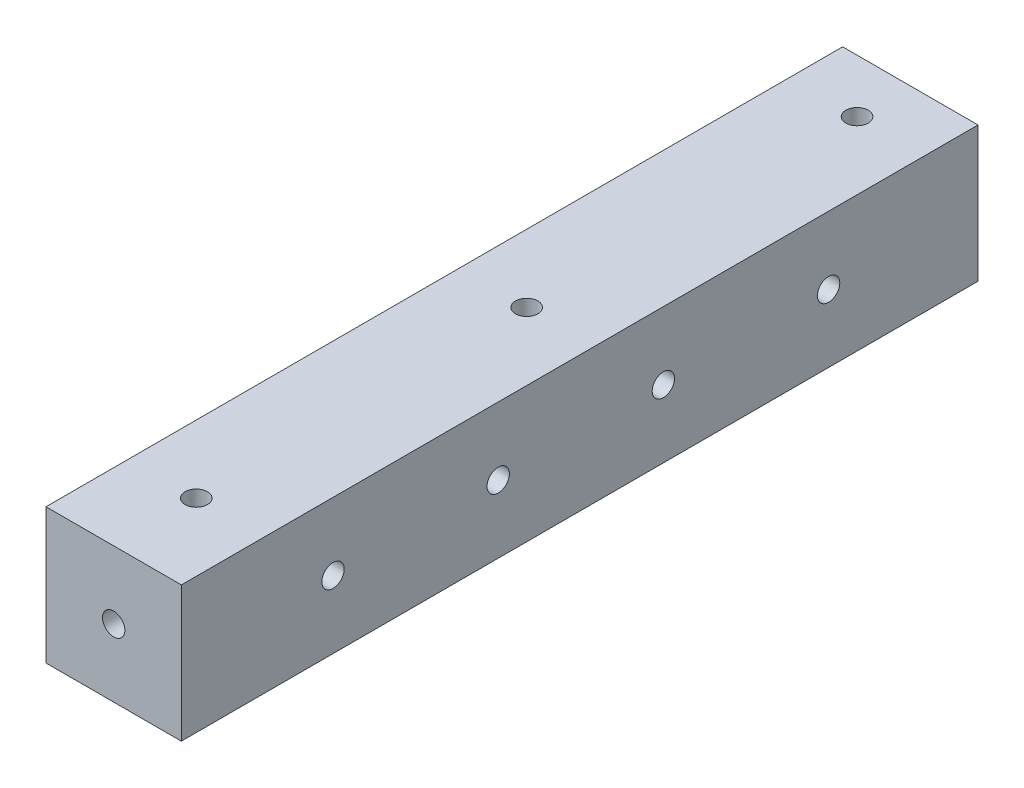
from build123d import *

# Parameters (mm, degrees)
SKETCH1_W                   = 25.4
SKETCH1_H                   = 25.4
BOSS_EXTRUDE1_DEPTH         = 77.5
M5X0_8_TAPPED_HOLE2_D       = 4.2
M5X0_8_TAPPED_HOLE1_D       = 4.2
M5X0_8_TAPPED_HOLE1_DEPTH   = 10
M5X0_8_TAPPED_HOLE1_TIP     = 1.2618073
SKETCH13_W                  = 25.4
SKETCH13_H                  = 5.5
CUT_EXTRUDE1_DEPTH          = 26.4
TAP_DRILL_FOR_M5X0_8_TAP1_D = 4.2


with BuildPart() as part:
    # Sketch1 → Boss-Extrude1 (new body, symmetric)
    with BuildSketch(Plane.XY):
        Rectangle(SKETCH1_W, SKETCH1_H)
    extrude(amount=BOSS_EXTRUDE1_DEPTH, both=True)

    # M5x0.8 Tapped Hole2 (through all)
    with Locations(Plane(origin=(0, -12.7, 0), x_dir=(-1, 0, 0), z_dir=(0, -1, 0))):
        with Locations((0, -62), (0, 0), (0, 62)):
            Hole(M5X0_8_TAPPED_HOLE2_D / 2)

    # M5x0.8 Tapped Hole1
    with Locations(Plane.XY.offset(77.5)):
        with Locations((0, 0)):
            Hole(M5X0_8_TAPPED_HOLE1_D / 2, depth=M5X0_8_TAPPED_HOLE1_DEPTH)
            with Locations((0, 0, -(M5X0_8_TAPPED_HOLE1_DEPTH + M5X0_8_TAPPED_HOLE1_TIP / 2))):  # 118° drill point
                Cone(0, M5X0_8_TAPPED_HOLE1_D / 2, M5X0_8_TAPPED_HOLE1_TIP, mode=Mode.SUBTRACT)

    # Sketch13 → Cut-Extrude1 (cut, through all)
    with BuildSketch(Plane(origin=(0, 12.7, 0), x_dir=(1, 0, 0), z_dir=(0, 1, 0))):
        with Locations((0, 74.75)):
            Rectangle(SKETCH13_W, SKETCH13_H)
    extrude(amount=-CUT_EXTRUDE1_DEPTH, mode=Mode.SUBTRACT)

    # Tap Drill for M5x0.8 Tap1 (through all)
    with Locations(Plane(origin=(12.7, 0, 0), x_dir=(0, 0, -1), z_dir=(1, 0, 0))):
        with Locations((-49.04, 0), (-18.04, 0), (12.96, 0), (43.96, 0)):
            Hole(TAP_DRILL_FOR_M5X0_8_TAP1_D / 2)


solid = part.part
